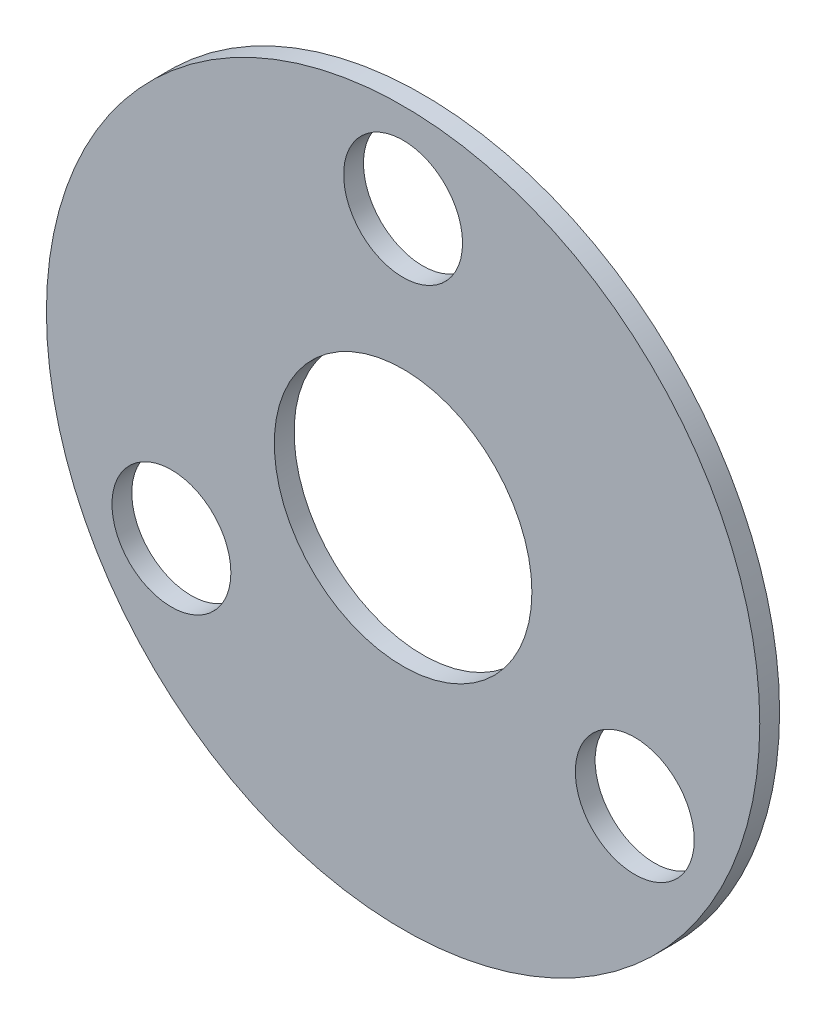
from build123d import *

# Parameters (mm, degrees)
CROQUIS1_R              = 18
SALIENTE_EXTRUIR2_DEPTH = 1
CROQUIS5_R              = 3
CROQUIS5_R_2            = 6.5
CORTAR_EXTRUIR3_DEPTH   = 1


with BuildPart() as part:
    # Croquis1 → Saliente-Extruir2 (new body)
    with BuildSketch(Plane.XY):
        Circle(CROQUIS1_R)
    extrude(amount=SALIENTE_EXTRUIR2_DEPTH)

    # Croquis5 → Cortar-Extruir3 (cut)
    with BuildSketch(Plane.XY.offset(1)):
        with Locations((0, 13.5)):
            Circle(CROQUIS5_R)
        with Locations((11.691342951, -6.75)):
            Circle(CROQUIS5_R)
        with Locations((-11.691342951, -6.75)):
            Circle(CROQUIS5_R)
        Circle(CROQUIS5_R_2)
    extrude(amount=-CORTAR_EXTRUIR3_DEPTH, mode=Mode.SUBTRACT)


solid = part.part
